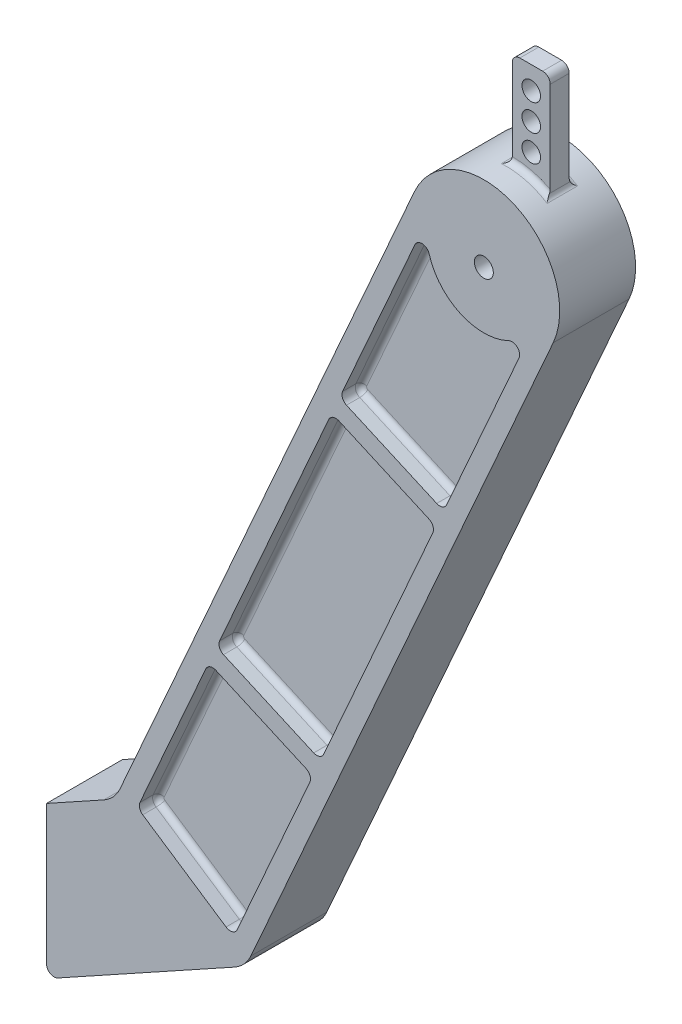
from build123d import *

# Parameters (mm, degrees)
SKETCH1_R           = 3.175
BOSS_EXTRUDE1_DEPTH = 12.7
CUT_EXTRUDE1_DEPTH  = 6.35
SKETCH3_R           = 3.1115
BOSS_EXTRUDE2_DEPTH = 3.175
FILLET1_R           = 1.905
FILLET2_R           = 1.905


with BuildPart() as part:
    # Sketch1 → Boss-Extrude1 (new body, symmetric)
    with BuildSketch(Plane.XY):
        with BuildLine():
            Line((-23.221886801, 10.290965621), (-121.74805685, -212.036428324))
            ThreePointArc((-121.74805685, -212.036428324), (-123.991527417, -215.466518539), (-127.210639188, -218.003445513))
            Line((-127.210639188, -218.003445513), (-146.362769413, -228.6))
            Line((-146.362769413, -228.6), (-146.362769413, -275.091803186))
            ThreePointArc((-146.362769413, -275.091803186), (-145.112775727, -277.279835112), (-142.593097201, -277.314303186))
            Line((-142.593097201, -277.314303186), (-83.42150114, -244.57564517))
            ThreePointArc((-83.42150114, -244.57564517), (-80.202389369, -242.038718195), (-77.958918802, -238.60862798))
            Line((-77.958918802, -238.60862798), (23.221886801, -10.290965621))
            ThreePointArc((23.221886801, -10.290965621), (10.290965621, 23.221886801), (-23.221886801, 10.290965621))
        make_face()
        Circle(SKETCH1_R, mode=Mode.SUBTRACT)
    extrude(amount=BOSS_EXTRUDE1_DEPTH, both=True)

    # Sketch2 → Cut-Extrude1 (cut)
    with BuildSketch(Plane.XY.offset(12.7)):
        with BuildLine():
            Line((-87.13098577, -155.86407995), (-56.942532929, -169.242335258))
            ThreePointArc((-56.942532929, -169.242335258), (-54.999082162, -169.289863098), (-53.591247687, -167.94924314))
            Line((-53.591247687, -167.94924314), (-17.058319731, -85.511544998))
            ThreePointArc((-17.058319731, -85.511544998), (-17.010791891, -83.568094231), (-18.351411849, -82.160259756))
            Line((-18.351411849, -82.160259756), (-48.53986469, -68.782004448))
            ThreePointArc((-48.53986469, -68.782004448), (-50.483315457, -68.734476608), (-51.891149932, -70.075096566))
            Line((-51.891149932, -70.075096566), (-88.424077888, -152.512794708))
            ThreePointArc((-88.424077888, -152.512794708), (-88.471605728, -154.456245476), (-87.13098577, -155.86407995))
        make_face()
        with BuildLine():
            Line((-45.967123284, -62.976532748), (-15.778670444, -76.354788056))
            ThreePointArc((-15.778670444, -76.354788056), (-13.835219676, -76.402315896), (-12.427385202, -75.061695938))
            Line((-12.427385202, -75.061695938), (11.779821091, -20.437375445))
            ThreePointArc((11.779821091, -20.437375445), (11.220804455, -17.579939651), (8.344969774, -17.124951955))
            ThreePointArc((8.344969774, -17.124951955), (-7.718224216, -17.4164151), (-18.291900379, -5.320609036))
            ThreePointArc((-18.291900379, -5.320609036), (-20.560656678, -3.495729926), (-23.05300911, -5.000927012))
            Line((-23.05300911, -5.000927012), (-47.260215402, -59.625247506))
            ThreePointArc((-47.260215402, -59.625247506), (-47.307743243, -61.568698273), (-45.967123284, -62.976532748))
        make_face()
        with BuildLine():
            Line((-89.703727175, -161.66955165), (-59.515274334, -175.047806958))
            ThreePointArc((-59.515274334, -175.047806958), (-58.174654376, -176.455641433), (-58.222182217, -178.3990922))
            Line((-58.222182217, -178.3990922), (-82.543211689, -233.280258269))
            ThreePointArc((-82.543211689, -233.280258269), (-84.155903931, -234.690057934), (-86.273182721, -234.365339762))
            Line((-86.273182721, -234.365339762), (-114.160951416, -215.795518496))
            ThreePointArc((-114.160951416, -215.795518496), (-115.192065291, -214.390836879), (-115.075357744, -212.652243879))
            Line((-115.075357744, -212.652243879), (-93.055012417, -162.962643768))
            ThreePointArc((-93.055012417, -162.962643768), (-91.647177943, -161.62202381), (-89.703727175, -161.66955165))
        make_face()
    cut_extrude1 = extrude(amount=-CUT_EXTRUDE1_DEPTH, mode=Mode.SUBTRACT)

    # Mirror1: Cut-Extrude1 across plane
    add(cut_extrude1.mirror(Plane.XY), mode=Mode.SUBTRACT)

    # Sketch3 → Boss-Extrude2 (add, symmetric)
    with BuildSketch(Plane.XY):
        with BuildLine():
            Line((0, 25.4), (0, 54.61))
            ThreePointArc((0, 54.61), (0.743948776, 56.406051224), (2.54, 57.15))
            Line((2.54, 57.15), (10.16, 57.15))
            ThreePointArc((10.16, 57.15), (11.956051224, 56.406051224), (12.7, 54.61))
            Line((12.7, 54.61), (12.7, 21.997045256))
            ThreePointArc((12.7, 21.997045256), (6.574003746, 24.534515988), (0, 25.4))
        make_face()
        with Locations((6.35, 49.53)):
            Circle(SKETCH3_R, mode=Mode.SUBTRACT)
        with Locations((6.35, 40.64)):
            Circle(SKETCH3_R, mode=Mode.SUBTRACT)
        with Locations((6.35, 31.75)):
            Circle(SKETCH3_R, mode=Mode.SUBTRACT)
    extrude(amount=BOSS_EXTRUDE2_DEPTH, both=True)

    # Fillet1
    fillet1_edges = [part.edges().sort_by_distance(p)[0] for p in [
        (6.574003746, 24.534515988, 3.175),
        (6.574003746, 24.534515988, -3.175),
        (0, 25.4, 0),
        (12.7, 21.997045256, 0),
    ]]
    fillet(fillet1_edges, radius=FILLET1_R)

    # Fillet2
    fillet2_edges = [part.edges().sort_by_distance(p)[0] for p in [
        (11.220804455, -17.579939651, -6.35),
        (-7.718224216, -17.4164151, -6.35),
        (-20.560656678, -3.495729926, -6.35),
        (-35.156612256, -32.313087259, -6.35),
        (-47.307743243, -61.568698273, -6.35),
        (-30.872896864, -69.665660402, -6.35),
        (-13.835219676, -76.402315896, -6.35),
        (-0.323782055, -47.749535691, -6.35),
        (-50.483315457, -68.734476608, -6.35),
        (-70.15761391, -111.293945637, -6.35),
        (-88.471605728, -154.456245476, -6.35),
        (-72.03675935, -162.553207604, -6.35),
        (-54.999082162, -169.289863098, -6.35),
        (-35.324783709, -126.730394069, -6.35),
        (-17.010791891, -83.568094231, -6.35),
        (-33.445638269, -75.471132102, -6.35),
        (-115.192065291, -214.390836879, -6.35),
        (-100.217067068, -225.080429129, -6.35),
        (-84.155903931, -234.690057934, -6.35),
        (-70.382696953, -205.839675235, -6.35),
        (-58.174654376, -176.455641433, -6.35),
        (-74.609500755, -168.358679304, -6.35),
        (-91.647177943, -161.62202381, -6.35),
        (-104.065185081, -187.807443824, -6.35),
        (11.220804455, -17.579939651, 6.35),
        (-0.323782055, -47.749535691, 6.35),
        (-13.835219676, -76.402315896, 6.35),
        (-30.872896864, -69.665660402, 6.35),
        (-47.307743243, -61.568698273, 6.35),
        (-35.156612256, -32.313087259, 6.35),
        (-20.560656678, -3.495729926, 6.35),
        (-7.718224216, -17.4164151, 6.35),
        (-50.483315457, -68.734476608, 6.35),
        (-33.445638269, -75.471132102, 6.35),
        (-17.010791891, -83.568094231, 6.35),
        (-35.324783709, -126.730394069, 6.35),
        (-54.999082162, -169.289863098, 6.35),
        (-72.03675935, -162.553207604, 6.35),
        (-88.471605728, -154.456245476, 6.35),
        (-70.15761391, -111.293945637, 6.35),
        (-115.192065291, -214.390836879, 6.35),
        (-104.065185081, -187.807443824, 6.35),
        (-91.647177943, -161.62202381, 6.35),
        (-74.609500755, -168.358679304, 6.35),
        (-58.174654376, -176.455641433, 6.35),
        (-70.382696953, -205.839675235, 6.35),
        (-84.155903931, -234.690057934, 6.35),
        (-100.217067068, -225.080429129, 6.35),
    ]]
    fillet(fillet2_edges, radius=FILLET2_R)


solid = part.part
